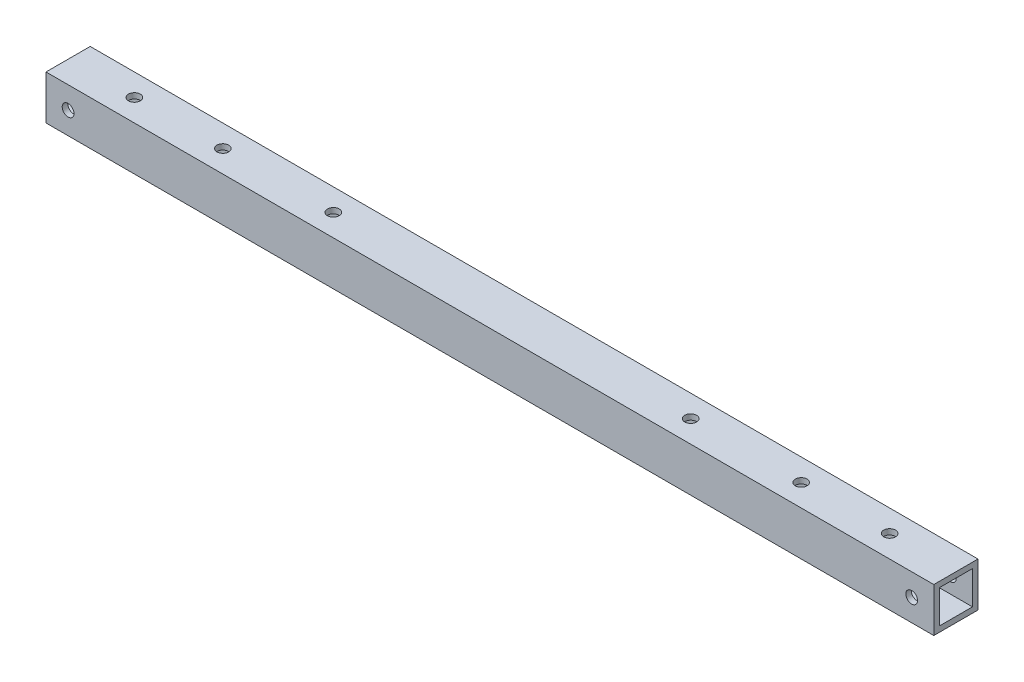
from build123d import *

# Parameters (mm, degrees)
SKETCH_1_W          = 12
SKETCH_1_H          = 12
SKETCH_1_W_2        = 9
SKETCH_1_H_2        = 9
EXTRUDE_1_DEPTH     = 241
SKETCH_2_R          = 1.6
CUT_EXTRUDE_1_DEPTH = 13
SKETCH_3_R          = 1.6
CUT_EXTRUDE_2_DEPTH = 13
SKETCH_4_R          = 1.6
CUT_EXTRUDE_3_DEPTH = 13


with BuildPart() as part:
    # ｽｹｯﾁ1 → ﾎﾞｽ - 押し出し1 (new body)
    with BuildSketch(Plane(origin=(0, 0, 0), x_dir=(0, 0, -1), z_dir=(1, 0, 0))):
        with Locations((6, 6)):
            Rectangle(SKETCH_1_W, SKETCH_1_H)
        with Locations((6, 6)):
            Rectangle(SKETCH_1_W_2, SKETCH_1_H_2, mode=Mode.SUBTRACT)
    extrude(amount=EXTRUDE_1_DEPTH)

    # ｽｹｯﾁ2 → ｶｯﾄ - 押し出し1 (cut, through all)
    with BuildSketch(Plane(origin=(0, 12, 0), x_dir=(1, 0, 0), z_dir=(0, 1, 0))):
        with Locations((18, 6)):
            Circle(SKETCH_2_R)
        with Locations((223, 6)):
            Circle(SKETCH_2_R)
    extrude(amount=-CUT_EXTRUDE_1_DEPTH, mode=Mode.SUBTRACT)

    # ｽｹｯﾁ3 → ｶｯﾄ - 押し出し2 (cut, through all)
    with BuildSketch(Plane.XY):
        with Locations((6, 6)):
            Circle(SKETCH_3_R)
        with Locations((235, 6)):
            Circle(SKETCH_3_R)
    extrude(amount=-CUT_EXTRUDE_2_DEPTH, mode=Mode.SUBTRACT)

    # ｽｹｯﾁ4 → ｶｯﾄ - 押し出し3 (cut, through all)
    with BuildSketch(Plane.XZ):
        with Locations((42, -6)):
            Circle(SKETCH_4_R)
        with Locations((72, -6)):
            Circle(SKETCH_4_R)
        with Locations((169, -6)):
            Circle(SKETCH_4_R)
        with Locations((199, -6)):
            Circle(SKETCH_4_R)
    extrude(amount=-CUT_EXTRUDE_3_DEPTH, mode=Mode.SUBTRACT)


solid = part.part
